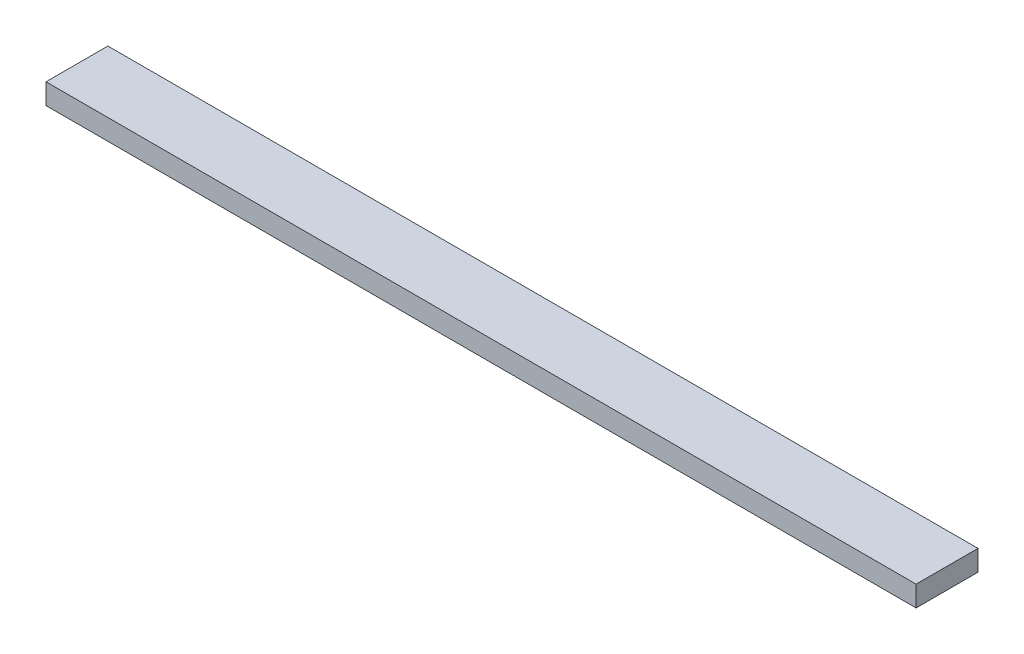
from build123d import *

# Parameters (mm, degrees)
SKETCH1_W              = 155.663706144
SKETCH1_H              = 4
BOSS_EXTRUDE1_DEPTH    = 10
BOSS_EXTRUDE4_DEPTH    = 10
FILLET1_R              = 0.5
LPATTERN1_COUNT        = 21
LPATTERN1_PITCH        = 6.283185307
FILLET1_OF_LPATTERN1_R = 0.5
BOSS_EXTRUDE6_DEPTH    = 6
SKETCH11_W             = 16
SKETCH11_H             = 4
BOSS_EXTRUDE8_DEPTH    = 10
SKETCH12_W             = 16
SKETCH12_H             = 4
BOSS_EXTRUDE9_DEPTH    = 10
SKETCH15_W             = 175.663706144
SKETCH15_H             = 16
BOSS_EXTRUDE10_DEPTH   = 5
BOSS_EXTRUDE11_DEPTH   = 4
SKETCH17_W             = 20
SKETCH17_H             = 9
BOSS_EXTRUDE12_DEPTH   = 10
SKETCH18_W             = 20
SKETCH18_H             = 9
CUT_EXTRUDE2_DEPTH     = 17
SKETCH19_W             = 170
SKETCH19_H             = 15
CUT_EXTRUDE3_DEPTH     = 8
SKETCH21_W             = 168.663706144
SKETCH21_H             = 4.5
CUT_EXTRUDE5_DEPTH     = 13
SKETCH20_W             = 12
SKETCH20_H             = 5
CUT_EXTRUDE4_DEPTH     = 169.663706144


with BuildPart() as part:
    # Sketch1 → Boss-Extrude1 (new body)
    with BuildSketch(Plane.XY):
        with Locations((0, 2)):
            Rectangle(SKETCH1_W, SKETCH1_H)
    extrude(amount=BOSS_EXTRUDE1_DEPTH)

    # Sketch2 → Boss-Extrude4 (add)
    with BuildSketch(Plane.XY):
        Polygon((-65.312574984, 4), (-63.67470893, 8.5), (-61.988997214, 8.5), (-60.351131159, 4), align=None)
    boss_extrude4 = extrude(amount=BOSS_EXTRUDE4_DEPTH)

    # Fillet1
    fillet1_edges = [part.edges().sort_by_distance(p)[0] for p in [
        (-60.351131159, 4, 5),
        (-65.312574984, 4, 5),
    ]]
    fillet(fillet1_edges, radius=FILLET1_R)

    # LPattern1: Boss-Extrude4 ×21
    with Locations(*[(i * LPATTERN1_PITCH, 0, 0) for i in range(1, LPATTERN1_COUNT)]):
        add(boss_extrude4)

    # Fillet1 of LPattern1
    fillet1_of_lpattern1_edges = [part.edges().sort_by_distance(p)[0] for p in [
        (-54.067945852, 4, 5),
        (-59.029389677, 4, 5),
        (-47.784760545, 4, 5),
        (-52.74620437, 4, 5),
        (-41.501575238, 4, 5),
        (-46.463019063, 4, 5),
        (-35.218389931, 4, 5),
        (-40.179833756, 4, 5),
        (-28.935204623, 4, 5),
        (-33.896648448, 4, 5),
        (-22.652019316, 4, 5),
        (-27.613463141, 4, 5),
        (-16.368834009, 4, 5),
        (-21.330277834, 4, 5),
        (-10.085648702, 4, 5),
        (-15.047092527, 4, 5),
        (-3.802463395, 4, 5),
        (-8.76390722, 4, 5),
        (2.480721912, 4, 5),
        (-2.480721912, 4, 5),
        (8.76390722, 4, 5),
        (3.802463395, 4, 5),
        (15.047092527, 4, 5),
        (10.085648702, 4, 5),
        (21.330277834, 4, 5),
        (16.368834009, 4, 5),
        (27.613463141, 4, 5),
        (22.652019316, 4, 5),
        (33.896648448, 4, 5),
        (28.935204623, 4, 5),
        (40.179833756, 4, 5),
        (35.218389931, 4, 5),
        (46.463019063, 4, 5),
        (41.501575238, 4, 5),
        (52.74620437, 4, 5),
        (47.784760545, 4, 5),
        (59.029389677, 4, 5),
        (54.067945852, 4, 5),
        (65.312574984, 4, 5),
        (60.351131159, 4, 5),
    ]]
    fillet(fillet1_of_lpattern1_edges, radius=FILLET1_OF_LPATTERN1_R)

    # Sketch9 → Boss-Extrude6 (add)
    with BuildSketch(Plane.XY.offset(10)):
        with BuildLine():
            Line((-77.831853072, 4), (-77.831853072, 0))
            Line((-77.831853072, 0), (77.831853072, 0))
            Line((77.831853072, 0), (77.831853072, 4))
            Line((77.831853072, 4), (65.662678753, 4))
            ThreePointArc((65.662678753, 4), (65.375890535, 4.090423978), (65.192832443, 4.328989928))
            Line((65.192832443, 4.328989928), (63.67470893, 8.5))
            Line((63.67470893, 8.5), (61.988997214, 8.5))
            Line((61.988997214, 8.5), (60.470873701, 4.328989928))
            ThreePointArc((60.470873701, 4.328989928), (60.287815608, 4.090423978), (60.00102739, 4))
            Line((60.00102739, 4), (59.379493446, 4))
            ThreePointArc((59.379493446, 4), (59.092705228, 4.090423978), (58.909647136, 4.328989928))
            Line((58.909647136, 4.328989928), (57.391523623, 8.5))
            Line((57.391523623, 8.5), (55.705811906, 8.5))
            Line((55.705811906, 8.5), (54.187688393, 4.328989928))
            ThreePointArc((54.187688393, 4.328989928), (54.004630301, 4.090423978), (53.717842083, 4))
            Line((53.717842083, 4), (53.096308139, 4))
            ThreePointArc((53.096308139, 4), (52.809519921, 4.090423978), (52.626461829, 4.328989928))
            Line((52.626461829, 4.328989928), (51.108338316, 8.5))
            Line((51.108338316, 8.5), (49.422626599, 8.5))
            Line((49.422626599, 8.5), (47.904503086, 4.328989928))
            ThreePointArc((47.904503086, 4.328989928), (47.721444994, 4.090423978), (47.434656776, 4))
            Line((47.434656776, 4), (46.813122832, 4))
            ThreePointArc((46.813122832, 4), (46.526334614, 4.090423978), (46.343276521, 4.328989928))
            Line((46.343276521, 4.328989928), (44.825153009, 8.5))
            Line((44.825153009, 8.5), (43.139441292, 8.5))
            Line((43.139441292, 8.5), (41.621317779, 4.328989928))
            ThreePointArc((41.621317779, 4.328989928), (41.438259687, 4.090423978), (41.151471469, 4))
            Line((41.151471469, 4), (40.529937525, 4))
            ThreePointArc((40.529937525, 4), (40.243149306, 4.090423978), (40.060091214, 4.328989928))
            Line((40.060091214, 4.328989928), (38.541967701, 8.5))
            Line((38.541967701, 8.5), (36.856255985, 8.5))
            Line((36.856255985, 8.5), (35.338132472, 4.328989928))
            ThreePointArc((35.338132472, 4.328989928), (35.15507438, 4.090423978), (34.868286162, 4))
            Line((34.868286162, 4), (34.246752217, 4))
            ThreePointArc((34.246752217, 4), (33.959963999, 4.090423978), (33.776905907, 4.328989928))
            Line((33.776905907, 4.328989928), (32.258782394, 8.5))
            Line((32.258782394, 8.5), (30.573070678, 8.5))
            Line((30.573070678, 8.5), (29.054947165, 4.328989928))
            ThreePointArc((29.054947165, 4.328989928), (28.871889073, 4.090423978), (28.585100854, 4))
            Line((28.585100854, 4), (27.96356691, 4))
            ThreePointArc((27.96356691, 4), (27.676778692, 4.090423978), (27.4937206, 4.328989928))
            Line((27.4937206, 4.328989928), (25.975597087, 8.5))
            Line((25.975597087, 8.5), (24.28988537, 8.5))
            Line((24.28988537, 8.5), (22.771761858, 4.328989928))
            ThreePointArc((22.771761858, 4.328989928), (22.588703765, 4.090423978), (22.301915547, 4))
            Line((22.301915547, 4), (21.680381603, 4))
            ThreePointArc((21.680381603, 4), (21.393593385, 4.090423978), (21.210535293, 4.328989928))
            Line((21.210535293, 4.328989928), (19.69241178, 8.5))
            Line((19.69241178, 8.5), (18.006700063, 8.5))
            Line((18.006700063, 8.5), (16.48857655, 4.328989928))
            ThreePointArc((16.48857655, 4.328989928), (16.305518458, 4.090423978), (16.01873024, 4))
            Line((16.01873024, 4), (15.397196296, 4))
            ThreePointArc((15.397196296, 4), (15.110408078, 4.090423978), (14.927349986, 4.328989928))
            Line((14.927349986, 4.328989928), (13.409226473, 8.5))
            Line((13.409226473, 8.5), (11.723514756, 8.5))
            Line((11.723514756, 8.5), (10.205391243, 4.328989928))
            ThreePointArc((10.205391243, 4.328989928), (10.022333151, 4.090423978), (9.735544933, 4))
            Line((9.735544933, 4), (9.114010989, 4))
            ThreePointArc((9.114010989, 4), (8.827222771, 4.090423978), (8.644164678, 4.328989928))
            Line((8.644164678, 4.328989928), (7.126041165, 8.5))
            Line((7.126041165, 8.5), (5.440329449, 8.5))
            Line((5.440329449, 8.5), (3.922205936, 4.328989928))
            ThreePointArc((3.922205936, 4.328989928), (3.739147844, 4.090423978), (3.452359626, 4))
            Line((3.452359626, 4), (2.830825682, 4))
            ThreePointArc((2.830825682, 4), (2.544037463, 4.090423978), (2.360979371, 4.328989928))
            Line((2.360979371, 4.328989928), (0.842855858, 8.5))
            Line((0.842855858, 8.5), (-0.842855858, 8.5))
            Line((-0.842855858, 8.5), (-2.360979371, 4.328989928))
            ThreePointArc((-2.360979371, 4.328989928), (-2.544037463, 4.090423978), (-2.830825682, 4))
            Line((-2.830825682, 4), (-3.452359626, 4))
            ThreePointArc((-3.452359626, 4), (-3.739147844, 4.090423978), (-3.922205936, 4.328989928))
            Line((-3.922205936, 4.328989928), (-5.440329449, 8.5))
            Line((-5.440329449, 8.5), (-7.126041165, 8.5))
            Line((-7.126041165, 8.5), (-8.644164678, 4.328989928))
            ThreePointArc((-8.644164678, 4.328989928), (-8.827222771, 4.090423978), (-9.114010989, 4))
            Line((-9.114010989, 4), (-9.735544933, 4))
            ThreePointArc((-9.735544933, 4), (-10.022333151, 4.090423978), (-10.205391243, 4.328989928))
            Line((-10.205391243, 4.328989928), (-11.723514756, 8.5))
            Line((-11.723514756, 8.5), (-13.409226473, 8.5))
            Line((-13.409226473, 8.5), (-14.927349986, 4.328989928))
            ThreePointArc((-14.927349986, 4.328989928), (-15.110408078, 4.090423978), (-15.397196296, 4))
            Line((-15.397196296, 4), (-16.01873024, 4))
            ThreePointArc((-16.01873024, 4), (-16.305518458, 4.090423978), (-16.48857655, 4.328989928))
            Line((-16.48857655, 4.328989928), (-18.006700063, 8.5))
            Line((-18.006700063, 8.5), (-19.69241178, 8.5))
            Line((-19.69241178, 8.5), (-21.210535293, 4.328989928))
            ThreePointArc((-21.210535293, 4.328989928), (-21.393593385, 4.090423978), (-21.680381603, 4))
            Line((-21.680381603, 4), (-22.301915547, 4))
            ThreePointArc((-22.301915547, 4), (-22.588703765, 4.090423978), (-22.771761858, 4.328989928))
            Line((-22.771761858, 4.328989928), (-24.28988537, 8.5))
            Line((-24.28988537, 8.5), (-25.975597087, 8.5))
            Line((-25.975597087, 8.5), (-27.4937206, 4.328989928))
            ThreePointArc((-27.4937206, 4.328989928), (-27.676778692, 4.090423978), (-27.96356691, 4))
            Line((-27.96356691, 4), (-28.585100854, 4))
            ThreePointArc((-28.585100854, 4), (-28.871889073, 4.090423978), (-29.054947165, 4.328989928))
            Line((-29.054947165, 4.328989928), (-30.573070678, 8.5))
            Line((-30.573070678, 8.5), (-32.258782394, 8.5))
            Line((-32.258782394, 8.5), (-33.776905907, 4.328989928))
            ThreePointArc((-33.776905907, 4.328989928), (-33.959963999, 4.090423978), (-34.246752217, 4))
            Line((-34.246752217, 4), (-34.868286162, 4))
            ThreePointArc((-34.868286162, 4), (-35.15507438, 4.090423978), (-35.338132472, 4.328989928))
            Line((-35.338132472, 4.328989928), (-36.856255985, 8.5))
            Line((-36.856255985, 8.5), (-38.541967701, 8.5))
            Line((-38.541967701, 8.5), (-40.060091214, 4.328989928))
            ThreePointArc((-40.060091214, 4.328989928), (-40.243149306, 4.090423978), (-40.529937525, 4))
            Line((-40.529937525, 4), (-41.151471469, 4))
            ThreePointArc((-41.151471469, 4), (-41.438259687, 4.090423978), (-41.621317779, 4.328989928))
            Line((-41.621317779, 4.328989928), (-43.139441292, 8.5))
            Line((-43.139441292, 8.5), (-44.825153009, 8.5))
            Line((-44.825153009, 8.5), (-46.343276521, 4.328989928))
            ThreePointArc((-46.343276521, 4.328989928), (-46.526334614, 4.090423978), (-46.813122832, 4))
            Line((-46.813122832, 4), (-47.434656776, 4))
            ThreePointArc((-47.434656776, 4), (-47.721444994, 4.090423978), (-47.904503086, 4.328989928))
            Line((-47.904503086, 4.328989928), (-49.422626599, 8.5))
            Line((-49.422626599, 8.5), (-51.108338316, 8.5))
            Line((-51.108338316, 8.5), (-52.626461829, 4.328989928))
            ThreePointArc((-52.626461829, 4.328989928), (-52.809519921, 4.090423978), (-53.096308139, 4))
            Line((-53.096308139, 4), (-53.717842083, 4))
            ThreePointArc((-53.717842083, 4), (-54.004630301, 4.090423978), (-54.187688393, 4.328989928))
            Line((-54.187688393, 4.328989928), (-55.705811906, 8.5))
            Line((-55.705811906, 8.5), (-57.391523623, 8.5))
            Line((-57.391523623, 8.5), (-58.909647136, 4.328989928))
            ThreePointArc((-58.909647136, 4.328989928), (-59.092705228, 4.090423978), (-59.379493446, 4))
            Line((-59.379493446, 4), (-60.00102739, 4))
            ThreePointArc((-60.00102739, 4), (-60.287815608, 4.090423978), (-60.470873701, 4.328989928))
            Line((-60.470873701, 4.328989928), (-61.988997214, 8.5))
            Line((-61.988997214, 8.5), (-63.67470893, 8.5))
            Line((-63.67470893, 8.5), (-65.192832443, 4.328989928))
            ThreePointArc((-65.192832443, 4.328989928), (-65.375890535, 4.090423978), (-65.662678753, 4))
            Line((-65.662678753, 4), (-77.831853072, 4))
        make_face()
    extrude(amount=BOSS_EXTRUDE6_DEPTH)

    # Sketch11 → Boss-Extrude8 (add)
    with BuildSketch(Plane.ZY.offset(77.831853072)):
        with Locations((8, 2)):
            Rectangle(SKETCH11_W, SKETCH11_H)
    extrude(amount=BOSS_EXTRUDE8_DEPTH)

    # Sketch12 → Boss-Extrude9 (add)
    with BuildSketch(Plane(origin=(77.831853072, 0, 0), x_dir=(0, 0, -1), z_dir=(1, 0, 0))):
        with Locations((-8, 2)):
            Rectangle(SKETCH12_W, SKETCH12_H)
    extrude(amount=BOSS_EXTRUDE9_DEPTH)

    # Sketch15 → Boss-Extrude10 (add)
    with BuildSketch(Plane.XZ):
        with Locations((0, 8)):
            Rectangle(SKETCH15_W, SKETCH15_H)
    extrude(amount=BOSS_EXTRUDE10_DEPTH)

    # Sketch16 → Boss-Extrude11 (add)
    with BuildSketch(Plane.XY.offset(16)):
        with BuildLine():
            Line((-61.988997214, 8.5), (-63.67470893, 8.5))
            Line((-63.67470893, 8.5), (-65.192832443, 4.328989928))
            ThreePointArc((-65.192832443, 4.328989928), (-65.375890535, 4.090423978), (-65.662678753, 4))
            Line((-65.662678753, 4), (-87.831853072, 4))
            Line((-87.831853072, 4), (-87.831853072, -5))
            Line((-87.831853072, -5), (87.831853072, -5))
            Line((87.831853072, -5), (87.831853072, 4))
            Line((87.831853072, 4), (65.662678753, 4))
            ThreePointArc((65.662678753, 4), (65.375890535, 4.090423978), (65.192832443, 4.328989928))
            Line((65.192832443, 4.328989928), (63.67470893, 8.5))
            Line((63.67470893, 8.5), (61.988997214, 8.5))
            Line((61.988997214, 8.5), (60.470873701, 4.328989928))
            ThreePointArc((60.470873701, 4.328989928), (60.287815608, 4.090423978), (60.00102739, 4))
            Line((60.00102739, 4), (59.379493446, 4))
            ThreePointArc((59.379493446, 4), (59.092705228, 4.090423978), (58.909647136, 4.328989928))
            Line((58.909647136, 4.328989928), (57.391523623, 8.5))
            Line((57.391523623, 8.5), (55.705811906, 8.5))
            Line((55.705811906, 8.5), (54.187688393, 4.328989928))
            ThreePointArc((54.187688393, 4.328989928), (54.004630301, 4.090423978), (53.717842083, 4))
            Line((53.717842083, 4), (53.096308139, 4))
            ThreePointArc((53.096308139, 4), (52.809519921, 4.090423978), (52.626461829, 4.328989928))
            Line((52.626461829, 4.328989928), (51.108338316, 8.5))
            Line((51.108338316, 8.5), (49.422626599, 8.5))
            Line((49.422626599, 8.5), (47.904503086, 4.328989928))
            ThreePointArc((47.904503086, 4.328989928), (47.721444994, 4.090423978), (47.434656776, 4))
            Line((47.434656776, 4), (46.813122832, 4))
            ThreePointArc((46.813122832, 4), (46.526334614, 4.090423978), (46.343276521, 4.328989928))
            Line((46.343276521, 4.328989928), (44.825153009, 8.5))
            Line((44.825153009, 8.5), (43.139441292, 8.5))
            Line((43.139441292, 8.5), (41.621317779, 4.328989928))
            ThreePointArc((41.621317779, 4.328989928), (41.438259687, 4.090423978), (41.151471469, 4))
            Line((41.151471469, 4), (40.529937525, 4))
            ThreePointArc((40.529937525, 4), (40.243149306, 4.090423978), (40.060091214, 4.328989928))
            Line((40.060091214, 4.328989928), (38.541967701, 8.5))
            Line((38.541967701, 8.5), (36.856255985, 8.5))
            Line((36.856255985, 8.5), (35.338132472, 4.328989928))
            ThreePointArc((35.338132472, 4.328989928), (35.15507438, 4.090423978), (34.868286162, 4))
            Line((34.868286162, 4), (34.246752217, 4))
            ThreePointArc((34.246752217, 4), (33.959963999, 4.090423978), (33.776905907, 4.328989928))
            Line((33.776905907, 4.328989928), (32.258782394, 8.5))
            Line((32.258782394, 8.5), (30.573070678, 8.5))
            Line((30.573070678, 8.5), (29.054947165, 4.328989928))
            ThreePointArc((29.054947165, 4.328989928), (28.871889073, 4.090423978), (28.585100854, 4))
            Line((28.585100854, 4), (27.96356691, 4))
            ThreePointArc((27.96356691, 4), (27.676778692, 4.090423978), (27.4937206, 4.328989928))
            Line((27.4937206, 4.328989928), (25.975597087, 8.5))
            Line((25.975597087, 8.5), (24.28988537, 8.5))
            Line((24.28988537, 8.5), (22.771761858, 4.328989928))
            ThreePointArc((22.771761858, 4.328989928), (22.588703765, 4.090423978), (22.301915547, 4))
            Line((22.301915547, 4), (21.680381603, 4))
            ThreePointArc((21.680381603, 4), (21.393593385, 4.090423978), (21.210535293, 4.328989928))
            Line((21.210535293, 4.328989928), (19.69241178, 8.5))
            Line((19.69241178, 8.5), (18.006700063, 8.5))
            Line((18.006700063, 8.5), (16.48857655, 4.328989928))
            ThreePointArc((16.48857655, 4.328989928), (16.305518458, 4.090423978), (16.01873024, 4))
            Line((16.01873024, 4), (15.397196296, 4))
            ThreePointArc((15.397196296, 4), (15.110408078, 4.090423978), (14.927349986, 4.328989928))
            Line((14.927349986, 4.328989928), (13.409226473, 8.5))
            Line((13.409226473, 8.5), (11.723514756, 8.5))
            Line((11.723514756, 8.5), (10.205391243, 4.328989928))
            ThreePointArc((10.205391243, 4.328989928), (10.022333151, 4.090423978), (9.735544933, 4))
            Line((9.735544933, 4), (9.114010989, 4))
            ThreePointArc((9.114010989, 4), (8.827222771, 4.090423978), (8.644164678, 4.328989928))
            Line((8.644164678, 4.328989928), (7.126041165, 8.5))
            Line((7.126041165, 8.5), (5.440329449, 8.5))
            Line((5.440329449, 8.5), (3.922205936, 4.328989928))
            ThreePointArc((3.922205936, 4.328989928), (3.739147844, 4.090423978), (3.452359626, 4))
            Line((3.452359626, 4), (2.830825682, 4))
            ThreePointArc((2.830825682, 4), (2.544037463, 4.090423978), (2.360979371, 4.328989928))
            Line((2.360979371, 4.328989928), (0.842855858, 8.5))
            Line((0.842855858, 8.5), (-0.842855858, 8.5))
            Line((-0.842855858, 8.5), (-2.360979371, 4.328989928))
            ThreePointArc((-2.360979371, 4.328989928), (-2.544037463, 4.090423978), (-2.830825682, 4))
            Line((-2.830825682, 4), (-3.452359626, 4))
            ThreePointArc((-3.452359626, 4), (-3.739147844, 4.090423978), (-3.922205936, 4.328989928))
            Line((-3.922205936, 4.328989928), (-5.440329449, 8.5))
            Line((-5.440329449, 8.5), (-7.126041165, 8.5))
            Line((-7.126041165, 8.5), (-8.644164678, 4.328989928))
            ThreePointArc((-8.644164678, 4.328989928), (-8.827222771, 4.090423978), (-9.114010989, 4))
            Line((-9.114010989, 4), (-9.735544933, 4))
            ThreePointArc((-9.735544933, 4), (-10.022333151, 4.090423978), (-10.205391243, 4.328989928))
            Line((-10.205391243, 4.328989928), (-11.723514756, 8.5))
            Line((-11.723514756, 8.5), (-13.409226473, 8.5))
            Line((-13.409226473, 8.5), (-14.927349986, 4.328989928))
            ThreePointArc((-14.927349986, 4.328989928), (-15.110408078, 4.090423978), (-15.397196296, 4))
            Line((-15.397196296, 4), (-16.01873024, 4))
            ThreePointArc((-16.01873024, 4), (-16.305518458, 4.090423978), (-16.48857655, 4.328989928))
            Line((-16.48857655, 4.328989928), (-18.006700063, 8.5))
            Line((-18.006700063, 8.5), (-19.69241178, 8.5))
            Line((-19.69241178, 8.5), (-21.210535293, 4.328989928))
            ThreePointArc((-21.210535293, 4.328989928), (-21.393593385, 4.090423978), (-21.680381603, 4))
            Line((-21.680381603, 4), (-22.301915547, 4))
            ThreePointArc((-22.301915547, 4), (-22.588703765, 4.090423978), (-22.771761858, 4.328989928))
            Line((-22.771761858, 4.328989928), (-24.28988537, 8.5))
            Line((-24.28988537, 8.5), (-25.975597087, 8.5))
            Line((-25.975597087, 8.5), (-27.4937206, 4.328989928))
            ThreePointArc((-27.4937206, 4.328989928), (-27.676778692, 4.090423978), (-27.96356691, 4))
            Line((-27.96356691, 4), (-28.585100854, 4))
            ThreePointArc((-28.585100854, 4), (-28.871889073, 4.090423978), (-29.054947165, 4.328989928))
            Line((-29.054947165, 4.328989928), (-30.573070678, 8.5))
            Line((-30.573070678, 8.5), (-32.258782394, 8.5))
            Line((-32.258782394, 8.5), (-33.776905907, 4.328989928))
            ThreePointArc((-33.776905907, 4.328989928), (-33.959963999, 4.090423978), (-34.246752217, 4))
            Line((-34.246752217, 4), (-34.868286162, 4))
            ThreePointArc((-34.868286162, 4), (-35.15507438, 4.090423978), (-35.338132472, 4.328989928))
            Line((-35.338132472, 4.328989928), (-36.856255985, 8.5))
            Line((-36.856255985, 8.5), (-38.541967701, 8.5))
            Line((-38.541967701, 8.5), (-40.060091214, 4.328989928))
            ThreePointArc((-40.060091214, 4.328989928), (-40.243149306, 4.090423978), (-40.529937525, 4))
            Line((-40.529937525, 4), (-41.151471469, 4))
            ThreePointArc((-41.151471469, 4), (-41.438259687, 4.090423978), (-41.621317779, 4.328989928))
            Line((-41.621317779, 4.328989928), (-43.139441292, 8.5))
            Line((-43.139441292, 8.5), (-44.825153009, 8.5))
            Line((-44.825153009, 8.5), (-46.343276521, 4.328989928))
            ThreePointArc((-46.343276521, 4.328989928), (-46.526334614, 4.090423978), (-46.813122832, 4))
            Line((-46.813122832, 4), (-47.434656776, 4))
            ThreePointArc((-47.434656776, 4), (-47.721444994, 4.090423978), (-47.904503086, 4.328989928))
            Line((-47.904503086, 4.328989928), (-49.422626599, 8.5))
            Line((-49.422626599, 8.5), (-51.108338316, 8.5))
            Line((-51.108338316, 8.5), (-52.626461829, 4.328989928))
            ThreePointArc((-52.626461829, 4.328989928), (-52.809519921, 4.090423978), (-53.096308139, 4))
            Line((-53.096308139, 4), (-53.717842083, 4))
            ThreePointArc((-53.717842083, 4), (-54.004630301, 4.090423978), (-54.187688393, 4.328989928))
            Line((-54.187688393, 4.328989928), (-55.705811906, 8.5))
            Line((-55.705811906, 8.5), (-57.391523623, 8.5))
            Line((-57.391523623, 8.5), (-58.909647136, 4.328989928))
            ThreePointArc((-58.909647136, 4.328989928), (-59.092705228, 4.090423978), (-59.379493446, 4))
            Line((-59.379493446, 4), (-60.00102739, 4))
            ThreePointArc((-60.00102739, 4), (-60.287815608, 4.090423978), (-60.470873701, 4.328989928))
            Line((-60.470873701, 4.328989928), (-61.988997214, 8.5))
        make_face()
    extrude(amount=BOSS_EXTRUDE11_DEPTH)

    # Sketch17 → Boss-Extrude12 (add)
    with BuildSketch(Plane(origin=(87.831853072, 0, 0), x_dir=(0, 0, -1), z_dir=(1, 0, 0))):
        with Locations((-10, -0.5)):
            Rectangle(SKETCH17_W, SKETCH17_H)
    extrude(amount=BOSS_EXTRUDE12_DEPTH)

    # Sketch18 → Cut-Extrude2 (cut)
    with BuildSketch(Plane.ZY.offset(87.831853072)):
        with Locations((10, -0.5)):
            Rectangle(SKETCH18_W, SKETCH18_H)
    extrude(amount=-CUT_EXTRUDE2_DEPTH, mode=Mode.SUBTRACT)

    # Sketch19 → Cut-Extrude3 (cut)
    with BuildSketch(Plane(origin=(0, 0, 0), x_dir=(-1, 0, 0), z_dir=(0, 0, -1))):
        with Locations((-12.831853072, 2.5)):
            Rectangle(SKETCH19_W, SKETCH19_H)
    extrude(amount=-CUT_EXTRUDE3_DEPTH, mode=Mode.SUBTRACT)

    # Sketch21 → Cut-Extrude5 (cut, through all)
    with BuildSketch(Plane(origin=(0, 0, 8), x_dir=(-1, 0, 0), z_dir=(0, 0, -1))):
        with Locations((-13.5, 6.25)):
            Rectangle(SKETCH21_W, SKETCH21_H)
    extrude(amount=-CUT_EXTRUDE5_DEPTH, mode=Mode.SUBTRACT)

    # Sketch20 → Cut-Extrude4 (cut, through all)
    with BuildSketch(Plane(origin=(97.831853072, 0, 0), x_dir=(0, 0, -1), z_dir=(1, 0, 0))):
        with Locations((-14, -2.5)):
            Rectangle(SKETCH20_W, SKETCH20_H)
    extrude(amount=-CUT_EXTRUDE4_DEPTH, mode=Mode.SUBTRACT)


solid = part.part
